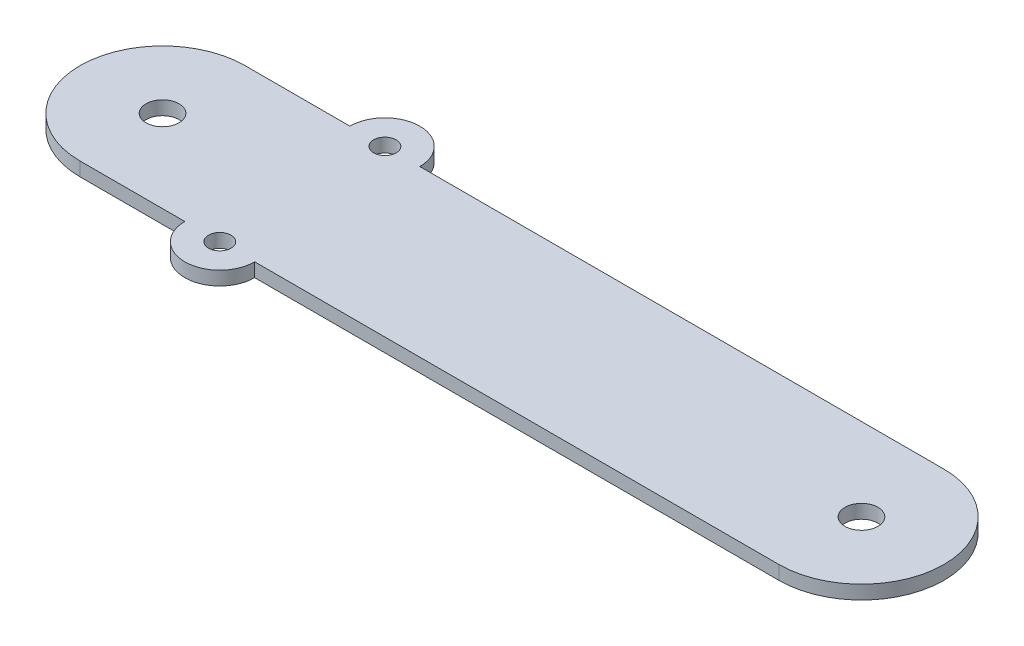
from build123d import *

# Parameters (mm, degrees)
BOSS_EXTRUDE1_DEPTH        = 2.5
F_12_0MM_DOWEL_HOLE1_D     = 12
F_12_0MM_DOWEL_HOLE1_DEPTH = 5
F_8_0MM_DOWEL_HOLE1_D      = 8.2
F_8_0MM_DOWEL_HOLE1_DEPTH  = 5


with BuildPart() as part:
    # Sketch1 → Boss-Extrude1 (new body, symmetric)
    with BuildSketch(Plane(origin=(0, 0, 0), x_dir=(1, 0, 0), z_dir=(0, 1, 0))):
        with BuildLine():
            Line((-88.9, 30), (-127, 30))
            ThreePointArc((-127, 30), (-157, 0), (-127, -30))
            Line((-127, -30), (-88.9, -30))
            ThreePointArc((-88.9, -30), (-76.2, -42.7), (-63.5, -30))
            Line((-63.5, -30), (127, -30))
            ThreePointArc((127, -30), (157, 0), (127, 30))
            Line((127, 30), (-63.5, 30))
            ThreePointArc((-63.5, 30), (-76.2, 42.7), (-88.9, 30))
        make_face()
    extrude(amount=BOSS_EXTRUDE1_DEPTH, both=True)

    # Ø12.0mm Dowel Hole1
    with Locations(Plane(origin=(0, 2.5, 0), x_dir=(1, 0, 0), z_dir=(0, 1, 0))):
        with Locations((-127, 0), (127, 0)):
            Hole(F_12_0MM_DOWEL_HOLE1_D / 2, depth=F_12_0MM_DOWEL_HOLE1_DEPTH)

    # Ø8.0mm Dowel Hole1
    with Locations(Plane(origin=(0, 2.5, 0), x_dir=(1, 0, 0), z_dir=(0, 1, 0))):
        with Locations((-76.2, 30), (-76.2, -30)):
            Hole(F_8_0MM_DOWEL_HOLE1_D / 2, depth=F_8_0MM_DOWEL_HOLE1_DEPTH)


solid = part.part
